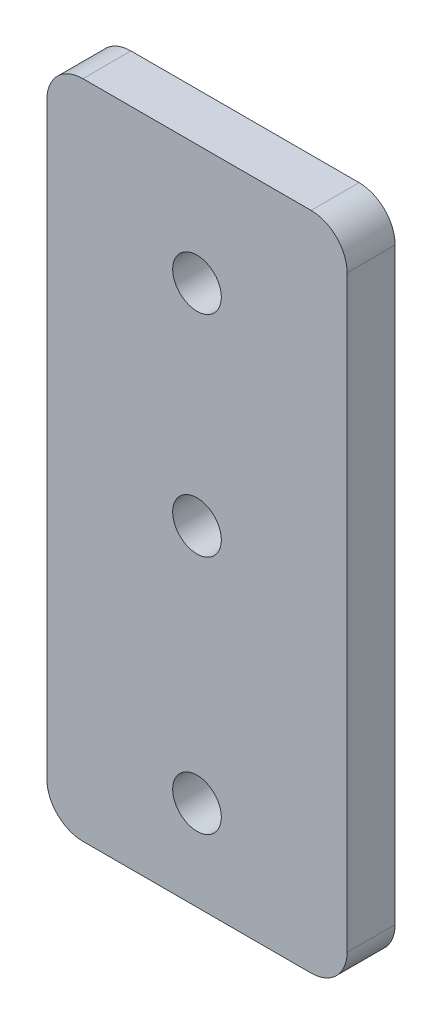
from build123d import *

# Parameters (mm, degrees)
SKETCH_1_W          = 25
SKETCH_1_H          = 55
EXTRUDE_1_DEPTH     = 2
SKETCH_2_R          = 2.025
CUT_EXTRUDE_1_DEPTH = 12
FILLET_1_R          = 3


with BuildPart() as part:
    # 草图1 → 凸台-拉伸1 (new body, symmetric)
    with BuildSketch(Plane.XY):
        Rectangle(SKETCH_1_W, SKETCH_1_H)
    extrude(amount=EXTRUDE_1_DEPTH, both=True)

    # 草图2 → 切除-拉伸1 (cut, symmetric)
    with BuildSketch(Plane.XY.offset(2)):
        with Locations((0, 17.5)):
            Circle(SKETCH_2_R)
        Circle(SKETCH_2_R)
        with Locations((0, -20)):
            Circle(SKETCH_2_R)
    extrude(amount=CUT_EXTRUDE_1_DEPTH, both=True, mode=Mode.SUBTRACT)

    # 圆角1
    fillet_1_edges = [part.edges().sort_by_distance(p)[0] for p in [
        (12.5, -27.5, 0),
        (-12.5, -27.5, 0),
        (-12.5, 27.5, 0),
        (12.5, 27.5, 0),
    ]]
    fillet(fillet_1_edges, radius=FILLET_1_R)


solid = part.part
